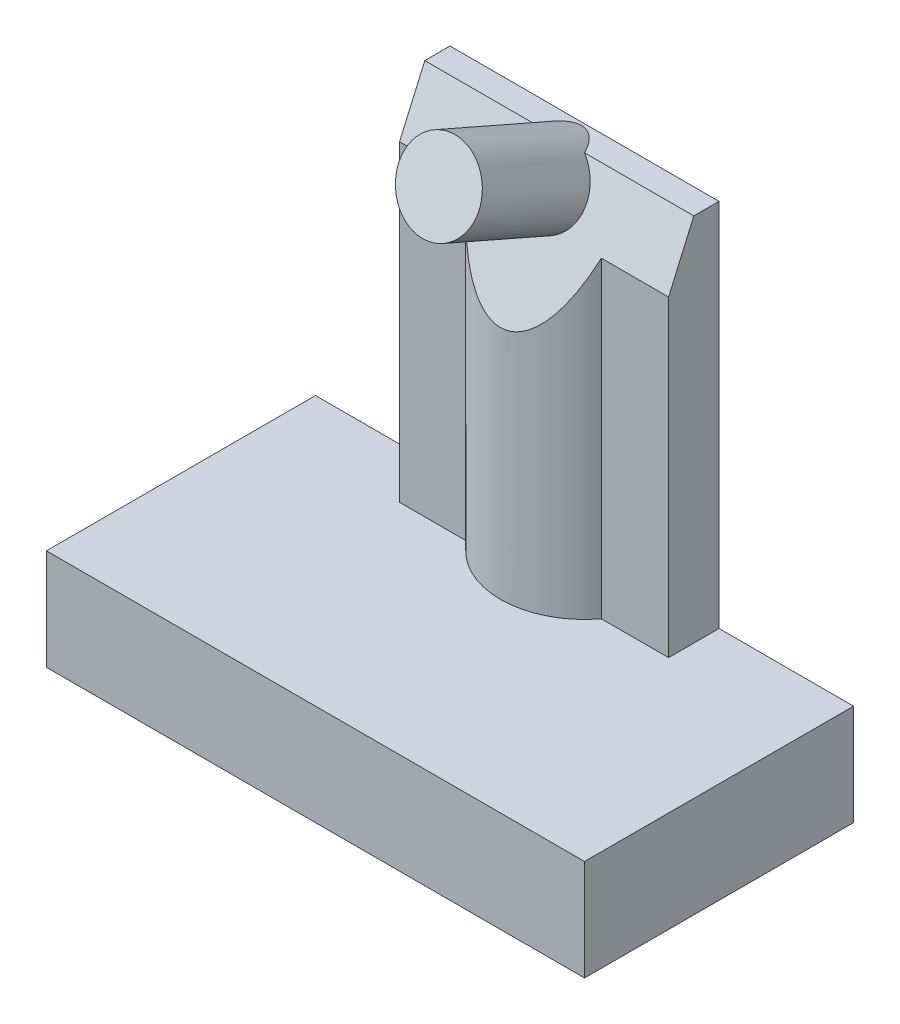
from build123d import *

# Parameters (mm, degrees)
SKETCH1_W                       = 16
SKETCH1_H                       = 8
BOSS_EXTRUDE1_DEPTH             = 3
SHELL1_T                        = -1
SKETCH3_R                       = 1.5
SKETCH3_R_2                     = 0.8
BOSS_EXTRUDE3_DEPTH             = 2
BOSS_EXTRUDE4_DEPTH             = 11
CUT_EXTRUDE1_DEPTH              = 11
BOSS_EXTRUDE5_REACH             = 8.299
SKETCH7_R                       = 1.2
BOSS_EXTRUDE5_DIRECTION_2_DEPTH = 3.5


with BuildPart() as part:
    # Sketch1 → Boss-Extrude1 (new body)
    with BuildSketch(Plane(origin=(0, 0, 0), x_dir=(1, 0, 0), z_dir=(0, 1, 0))):
        with Locations((8, 4)):
            Rectangle(SKETCH1_W, SKETCH1_H)
    extrude(amount=BOSS_EXTRUDE1_DEPTH)

    # Shell1
    shell1_openings = [part.faces().sort_by_distance(p)[0] for p in [
        (8, 0, -4),
    ]]
    offset(amount=SHELL1_T, openings=shell1_openings, kind=Kind.INTERSECTION)

    # Sketch3 → Boss-Extrude3 (add)
    with BuildSketch(Plane.XZ.offset(-2)):
        with Locations(Location((8, -4, 0), (0, 0, 270))):  # turned: the seam where the file's is
            Circle(SKETCH3_R)
        with Locations(Location((8, -4, 0), (0, 0, 270))):  # turned: the seam where the file's is
            Circle(SKETCH3_R_2, mode=Mode.SUBTRACT)
    extrude(amount=BOSS_EXTRUDE3_DEPTH)

    # Sketch4 → Boss-Extrude4 (add)
    with BuildSketch(Plane(origin=(0, 3, 0), x_dir=(1, 0, 0), z_dir=(0, 1, 0))):
        with BuildLine():
            Line((4, 8), (12, 8))
            Line((12, 8), (12, 6.5))
            Line((12, 6.5), (10, 6.5))
            ThreePointArc((10, 6.5), (8, 5.5), (6, 6.5))
            Line((6, 6.5), (4, 6.5))
            Line((4, 6.5), (4, 8))
        make_face()
    extrude(amount=BOSS_EXTRUDE4_DEPTH)

    # Sketch6 → Cut-Extrude1 (cut)
    with BuildSketch(Plane(origin=(12, 0, 0), x_dir=(0, 0, -1), z_dir=(1, 0, 0))):
        Polygon((7.25, 14), (5.5, 14), (5.5, 10), align=None)
    extrude(amount=-CUT_EXTRUDE1_DEPTH, mode=Mode.SUBTRACT)

    # Sketch7 → Boss-Extrude5 (add, up to next)
    with BuildSketch(Plane(origin=(0, -0.413114754, -0.944262295), x_dir=(1, 0, 0), z_dir=(0, 0.400818834, 0.916157335)), mode=Mode.PRIVATE) as boss_extrude5_sk1:
        with Locations(Location((8, 14.796554457, 0), (0, 0, 51.228905229))):  # turned: the seam where the file's is
            Circle(SKETCH7_R)
    boss_extrude5_tool1 = extrude(boss_extrude5_sk1.sketch, amount=-BOSS_EXTRUDE5_REACH, mode=Mode.PRIVATE) - part.part
    add(boss_extrude5_tool1.solids().sort_by_distance((8, 13.142857, -6.875))[0])

    # Sketch7 → Boss-Extrude5 direction 2 (add)
    with BuildSketch(Plane(origin=(0, -0.413114754, -0.944262295), x_dir=(1, 0, 0), z_dir=(0, 0.400818834, 0.916157335))):
        with Locations(Location((8, 14.796554457, 0), (0, 0, 51.228905229))):  # turned: the seam where the file's is
            Circle(SKETCH7_R)
    extrude(amount=BOSS_EXTRUDE5_DIRECTION_2_DEPTH)


solid = part.part
